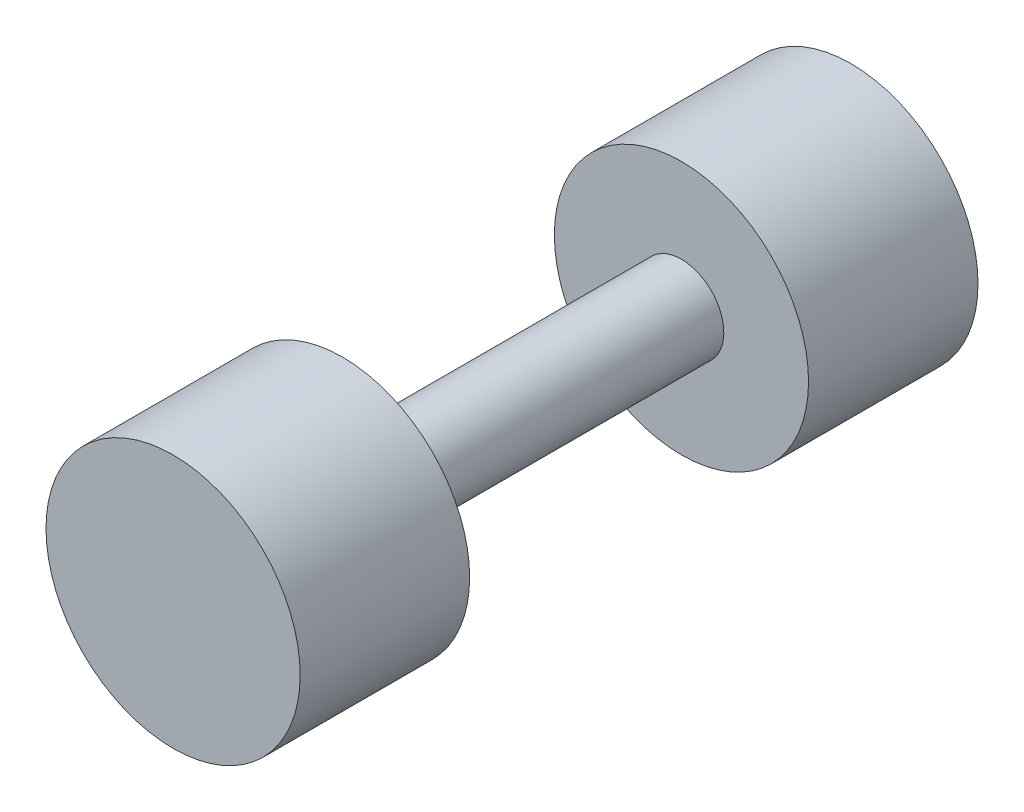
from build123d import *


with BuildPart() as part:
    # Sketch1 → Revolve1 (revolve)
    with BuildSketch(Plane(origin=(0, 0, 0), x_dir=(0, 0, -1), z_dir=(1, 0, 0))):
        Polygon((50.8, 0), (-50.8, 0), (-50.8, 19.05), (-25.4, 19.05), (-25.4, 6.35), (25.4, 6.35), (25.4, 19.05), (50.8, 19.05), align=None)
    revolve(axis=Axis((0, 0, -50.8), (0, 0, 1)))


solid = part.part
